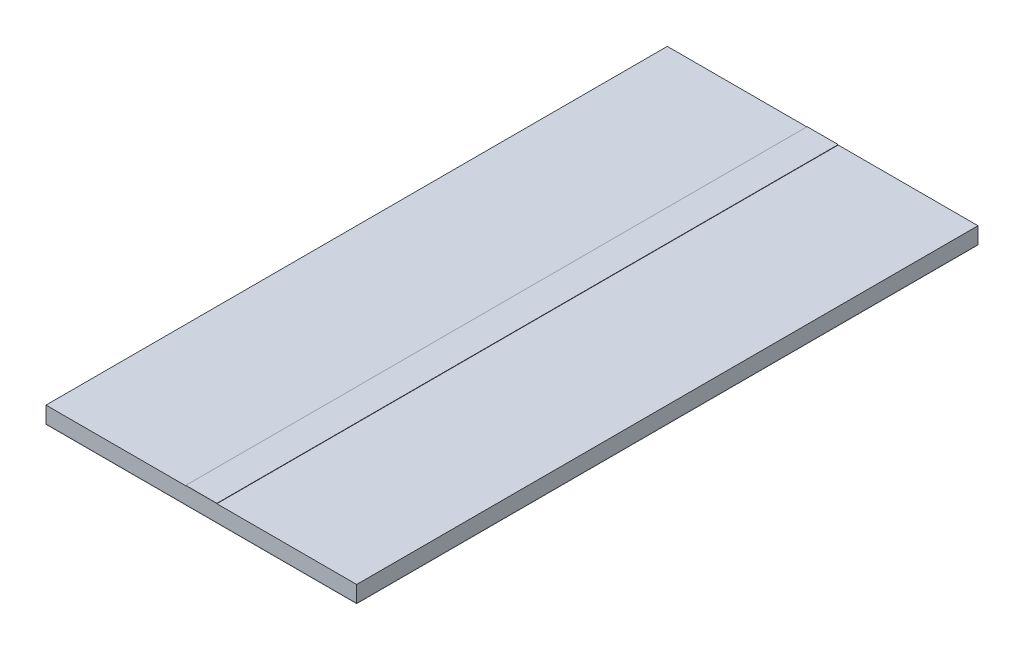
from build123d import *

# Parameters (mm, degrees)
SKETCH2_W           = 30
SKETCH2_H           = 60
BOSS_EXTRUDE1_DEPTH = 0.03556
SKETCH3_W           = 30
SKETCH3_H           = 60
BOSS_EXTRUDE2_DEPTH = 1.57
SKETCH4_W           = 3
SKETCH4_H           = 60
BOSS_EXTRUDE3_DEPTH = 0.03556


with BuildPart() as part:
    # Sketch2 → Boss-Extrude1 (new body)
    with BuildSketch(Plane(origin=(0, 0, 0), x_dir=(1, 0, 0), z_dir=(0, 1, 0))):
        Rectangle(SKETCH2_W, SKETCH2_H)
    extrude(amount=BOSS_EXTRUDE1_DEPTH)


with BuildPart() as body_2:
    # Sketch3 → Boss-Extrude2 (new body)
    with BuildSketch(Plane(origin=(0, 0.03556, 0), x_dir=(1, 0, 0), z_dir=(0, 1, 0))):
        Rectangle(SKETCH3_W, SKETCH3_H)
    extrude(amount=BOSS_EXTRUDE2_DEPTH)


with BuildPart() as body_3:
    # Sketch4 → Boss-Extrude3 (new body)
    with BuildSketch(Plane(origin=(0, 1.60556, 0), x_dir=(1, 0, 0), z_dir=(0, 1, 0))):
        Rectangle(SKETCH4_W, SKETCH4_H)
    extrude(amount=BOSS_EXTRUDE3_DEPTH)


solid = Compound([part.part, body_2.part, body_3.part])
